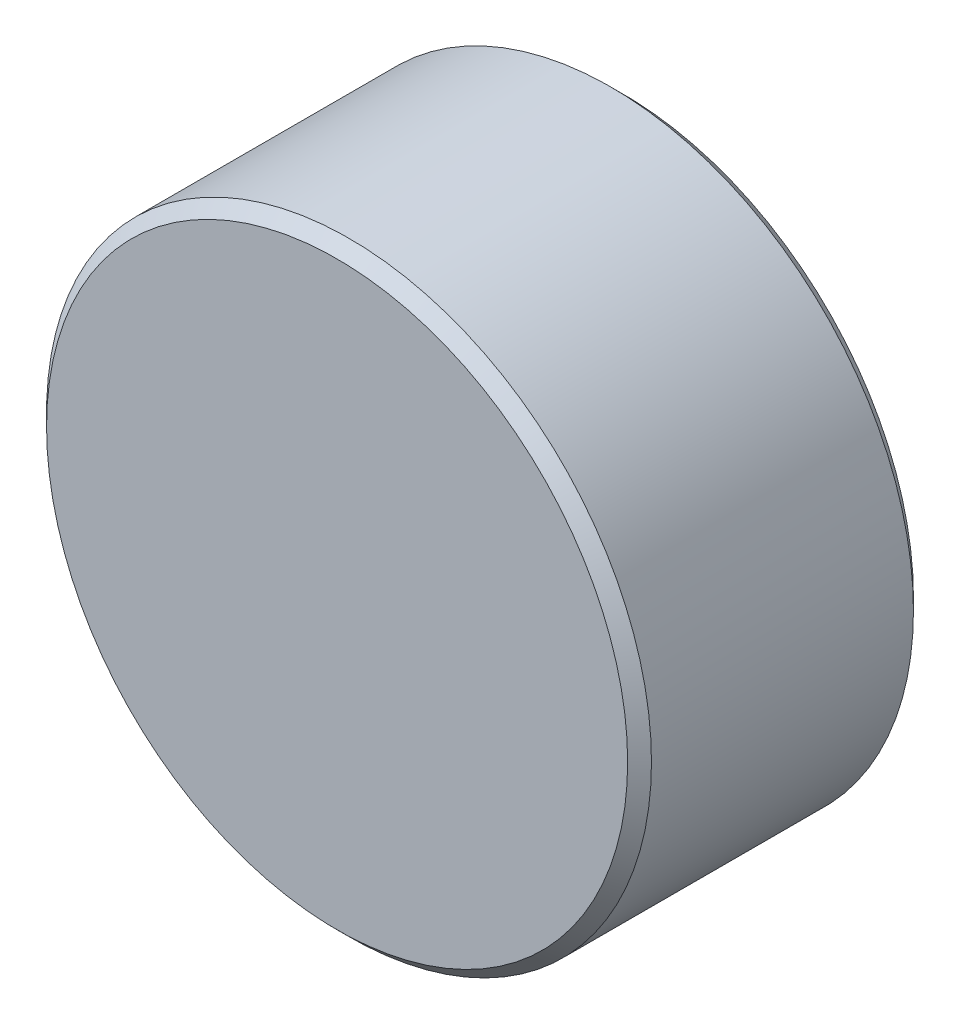
from build123d import *

# Parameters (mm, degrees)
SKETCH18_R          = 6.35
BOSS_EXTRUDE2_DEPTH = 3
CHAMFER4_SIZE       = 0.25


with BuildPart() as part:
    # Sketch18 → Boss-Extrude2 (new body, symmetric)
    with BuildSketch(Plane.XY):
        Circle(SKETCH18_R)
    extrude(amount=BOSS_EXTRUDE2_DEPTH, both=True)

    # Chamfer4
    chamfer4_edges = [part.edges().sort_by_distance(p)[0] for p in [
        (-6.35, 0, -3),
        (-6.35, 0, 3),
    ]]
    chamfer(chamfer4_edges, length=CHAMFER4_SIZE)


solid = part.part
